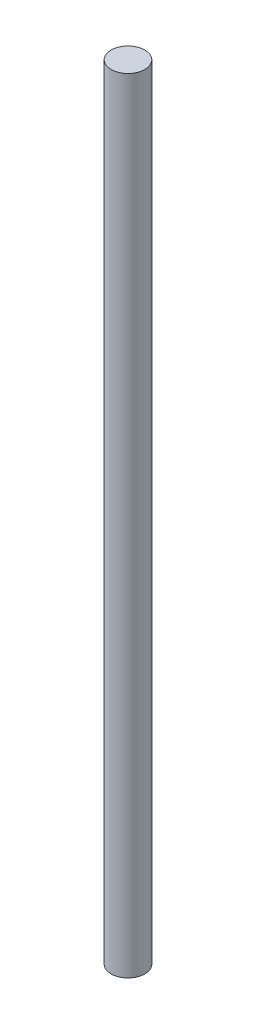
from build123d import *

# Parameters (mm, degrees)
CROQUIS1_R              = 4
SALIENTE_EXTRUIR1_DEPTH = 186


with BuildPart() as part:
    # Croquis1 → Saliente-Extruir1 (new body)
    with BuildSketch(Plane(origin=(0, 0, 0), x_dir=(1, 0, 0), z_dir=(0, 1, 0))):
        Circle(CROQUIS1_R)
    extrude(amount=SALIENTE_EXTRUIR1_DEPTH)


solid = part.part
